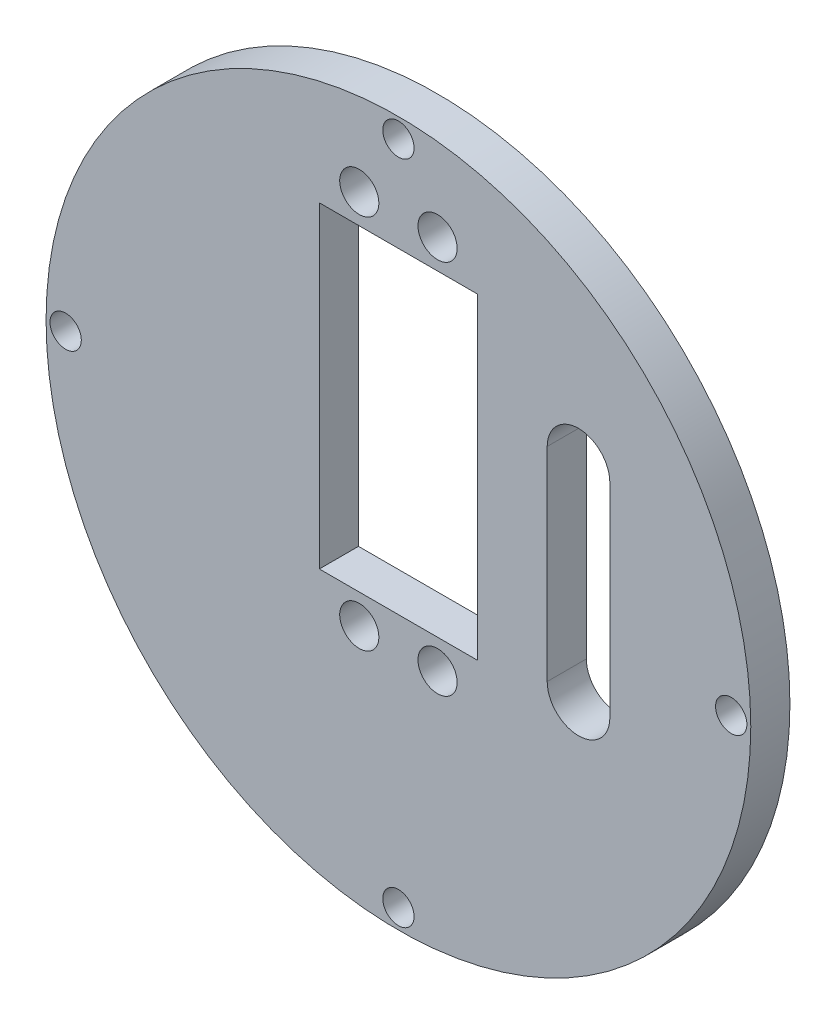
from build123d import *

# Parameters (mm, degrees)
SKETCH1_R           = 45
SKETCH1_R_2         = 2
SKETCH1_R_3         = 2.5
SKETCH1_W           = 20.2
SKETCH1_H           = 40.5
BOSS_EXTRUDE1_DEPTH = 5
CUT_EXTRUDE1_DEPTH  = 10


with BuildPart() as part:
    # Sketch1 → Boss-Extrude1 (new body)
    with BuildSketch(Plane.XY):
        Circle(SKETCH1_R)
        with Locations((0, 42.5)):
            Circle(SKETCH1_R_2, mode=Mode.SUBTRACT)
        with Locations((-42.5, 0)):
            Circle(SKETCH1_R_2, mode=Mode.SUBTRACT)
        with Locations((0, -42.5)):
            Circle(SKETCH1_R_2, mode=Mode.SUBTRACT)
        with Locations((42.5, 0)):
            Circle(SKETCH1_R_2, mode=Mode.SUBTRACT)
        with Locations((-5, -13.85)):
            Circle(SKETCH1_R_3, mode=Mode.SUBTRACT)
        with Locations((5, -13.85)):
            Circle(SKETCH1_R_3, mode=Mode.SUBTRACT)
        with Locations((5, 34.15)):
            Circle(SKETCH1_R_3, mode=Mode.SUBTRACT)
        with Locations((-5, 34.15)):
            Circle(SKETCH1_R_3, mode=Mode.SUBTRACT)
        with Locations((0, 10.15)):
            Rectangle(SKETCH1_W, SKETCH1_H, mode=Mode.SUBTRACT)
    extrude(amount=BOSS_EXTRUDE1_DEPTH)

    # Sketch2 → Cut-Extrude1 (cut)
    with BuildSketch(Plane.XY.offset(5)):
        with BuildLine():
            Line((27, 18), (27, -8))
            ThreePointArc((27, -8), (23, -12), (19, -8))
            Line((19, -8), (19, 18))
            ThreePointArc((19, 18), (23, 22), (27, 18))
        make_face()
    extrude(amount=-CUT_EXTRUDE1_DEPTH, mode=Mode.SUBTRACT)


solid = part.part
